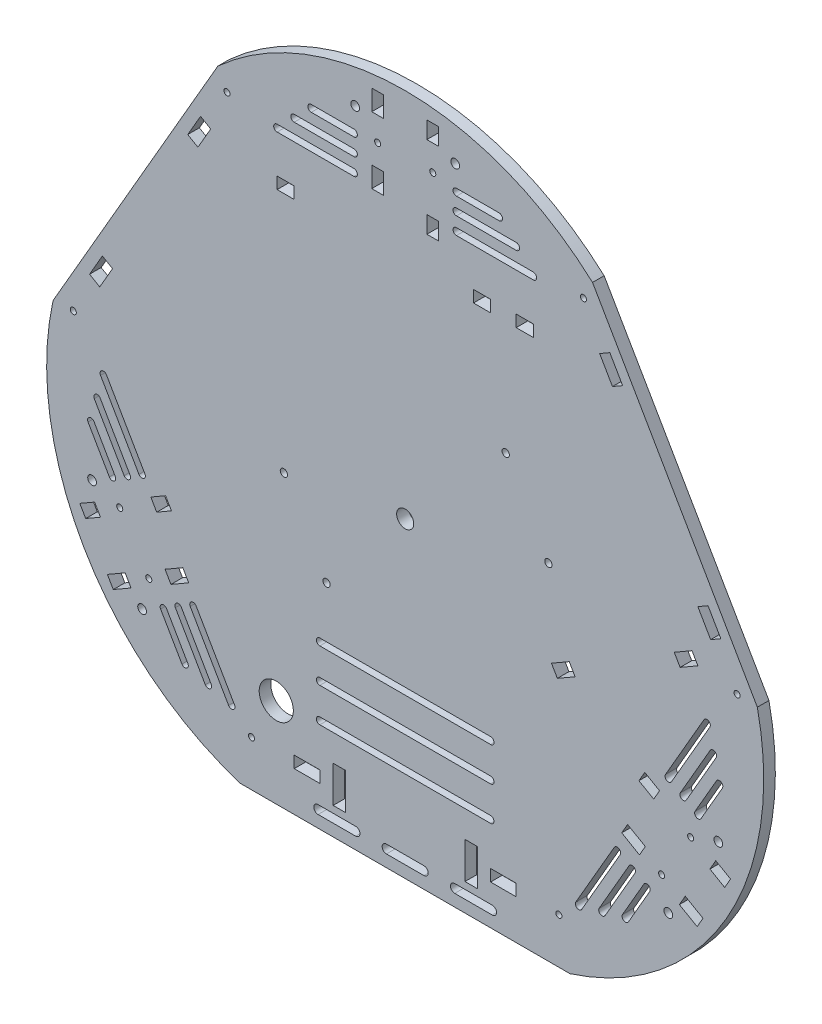
from build123d import *

# Parameters (mm, degrees)
SKETCH1_R           = 5
BOSS_EXTRUDE1_DEPTH = 6.8
SKETCH2_R           = 1.775
CUT_EXTRUDE1_DEPTH  = 6.8
SKETCH3_R           = 1.775
SKETCH3_W           = 15
SKETCH3_H           = 6.88
SKETCH3_W_2         = 7.2
SKETCH3_H_2         = 21.4
CUT_EXTRUDE2_DEPTH  = 6.8
CUT_EXTRUDE3_DEPTH  = 6.8
CUT_EXTRUDE4_DEPTH  = 6.8
SKETCH6_R           = 1.775
CUT_EXTRUDE5_DEPTH  = 6.8
CIRPATTERN1_COUNT   = 3
SKETCH7_R           = 2.55
CUT_EXTRUDE6_DEPTH  = 6.8
CIRPATTERN2_COUNT   = 3
SKETCH8_W           = 10
SKETCH8_H           = 6.88
CUT_EXTRUDE7_DEPTH  = 6.8
SKETCH10_R          = 10
CUT_EXTRUDE9_DEPTH  = 6.8
SKETCH11_R          = 2.125
CUT_EXTRUDE10_DEPTH = 10
CUT_EXTRUDE11_DEPTH = 7.8
CIRPATTERN4_COUNT   = 3
LPATTERN1_COUNT     = 2
LPATTERN1_PITCH     = 20
LPATTERN1_COL_COUNT = 2
LPATTERN1_COL_PITCH = 20
CUT_EXTRUDE12_DEPTH = 7.8


with BuildPart() as part:
    # Sketch1 → Boss-Extrude1 (new body)
    with BuildSketch(Plane.XY):
        with BuildLine():
            Line((-96.50625, -182.3938), (96.50625, -182.3938))
            ThreePointArc((96.50625, -182.3938), (188.115509518, -108.608540059), (206.210789293, 7.620035876))
            Line((206.210789293, 7.620035876), (109.704539293, 174.773764124))
            ThreePointArc((109.704539293, 174.773764124), (0, 217.217080118), (-109.704539293, 174.773764124))
            Line((-109.704539293, 174.773764124), (-206.210789293, 7.620035876))
            ThreePointArc((-206.210789293, 7.620035876), (-188.115509518, -108.608540059), (-96.50625, -182.3938))
        make_face()
        Circle(SKETCH1_R, mode=Mode.SUBTRACT)
    extrude(amount=BOSS_EXTRUDE1_DEPTH)

    # Sketch2 → Cut-Extrude1 (cut)
    with BuildSketch(Plane.XY.offset(6.8)):
        with Locations((-104.349371779, 164.169186341)):
            Circle(SKETCH2_R)
        with Locations((-194.349371779, 8.284613659)):
            Circle(SKETCH2_R)
        Polygon((-119.828499168, 144.238551246), (-127.328499168, 131.248170189), (-121.37024439, 127.808170189), (-113.87024439, 140.798551246), align=None)
        Polygon((-177.328499168, 44.645629811), (-171.37024439, 41.205629811), (-178.87024439, 28.215248754), (-184.828499168, 31.655248754), align=None)
    cut_extrude1 = extrude(amount=-CUT_EXTRUDE1_DEPTH, mode=Mode.SUBTRACT)

    # Sketch3 → Cut-Extrude2 (cut)
    with BuildSketch(Plane.XY.offset(6.8)):
        with Locations((-90, -155.7038)):
            Circle(SKETCH3_R)
        with Locations((-57.5, -155.7038)):
            Rectangle(SKETCH3_W, SKETCH3_H)
        with Locations((-38.6, -155.7038)):
            Rectangle(SKETCH3_W_2, SKETCH3_H_2)
    cut_extrude2 = extrude(amount=-CUT_EXTRUDE2_DEPTH, mode=Mode.SUBTRACT)

    # Sketch4 → Cut-Extrude3 (cut)
    with BuildSketch(Plane.XY.offset(6.8)):
        with BuildLine():
            Line((11, -175.3938), (-11, -175.3938))
            ThreePointArc((-11, -175.3938), (-13.5, -172.8938), (-11, -170.3938))
            Line((-11, -170.3938), (11, -170.3938))
            ThreePointArc((11, -170.3938), (13.5, -172.8938), (11, -175.3938))
        make_face()
        with BuildLine():
            Line((-29, -175.3938), (-51, -175.3938))
            ThreePointArc((-51, -175.3938), (-53.5, -172.8938), (-51, -170.3938))
            Line((-51, -170.3938), (-29, -170.3938))
            ThreePointArc((-29, -170.3938), (-26.5, -172.8938), (-29, -175.3938))
        make_face()
    cut_extrude3 = extrude(amount=-CUT_EXTRUDE3_DEPTH, mode=Mode.SUBTRACT)

    # Sketch5 → Cut-Extrude4 (cut)
    with BuildSketch(Plane.XY.offset(6.8)):
        with BuildLine():
            Line((50, -109.3938), (-50, -109.3938))
            ThreePointArc((-50, -109.3938), (-52, -107.3938), (-50, -105.3938))
            Line((-50, -105.3938), (50, -105.3938))
            ThreePointArc((50, -105.3938), (52, -107.3938), (50, -109.3938))
        make_face()
    cut_extrude4 = extrude(amount=-CUT_EXTRUDE4_DEPTH, mode=Mode.SUBTRACT)

    # Mirror1: Cut-Extrude1, Cut-Extrude2, Cut-Extrude3 across plane
    add(cut_extrude1.mirror(Plane(origin=(0, 0, 0), x_dir=(0, 0, 1), z_dir=(1, 0, 0))), mode=Mode.SUBTRACT)
    add(cut_extrude2.mirror(Plane(origin=(0, 0, 0), x_dir=(0, 0, 1), z_dir=(1, 0, 0))), mode=Mode.SUBTRACT)
    add(cut_extrude3.mirror(Plane(origin=(0, 0, 0), x_dir=(0, 0, 1), z_dir=(1, 0, 0))), mode=Mode.SUBTRACT)

    # Sketch6 → Cut-Extrude5 (cut)
    with BuildSketch(Plane.XY.offset(6.8)):
        with Locations((-150.152841271, -105.327650017)):
            Circle(SKETCH6_R)
        with Locations((-167.158866675, -77.872349983)):
            Circle(SKETCH6_R)
        Polygon((-187.08950177, -93.351477372), (-178.429247732, -88.351477372), (-181.869247732, -82.393222594), (-190.52950177, -87.393222594), align=None)
        Polygon((-174.38950177, -115.348522628), (-170.94950177, -121.306777406), (-160.557196924, -115.306777406), (-163.997196924, -109.348522628), align=None)
        Polygon((-148.960282388, -63.393222594), (-140.30002835, -58.393222594), (-136.86002835, -64.351477372), (-145.520282388, -69.351477372), align=None)
        Polygon((-140.614511022, -95.848522628), (-130.222206177, -89.848522628), (-126.782206177, -95.806777406), (-137.174511022, -101.806777406), align=None)
    cut_extrude5 = extrude(amount=-CUT_EXTRUDE5_DEPTH, mode=Mode.SUBTRACT)

    # Mirror2: Cut-Extrude5 across plane
    add(cut_extrude5.mirror(Plane(origin=(0, 0, 0), x_dir=(0, 0, 1), z_dir=(1, 0, 0))), mode=Mode.SUBTRACT)

    # CirPattern1: Cut-Extrude5 ×3 about axis, 1 skipped
    cirpattern1_axis = Axis((0, 0, 6.8), (0, 0, 1))
    add([cut_extrude5.rotate(cirpattern1_axis, i * 360 / CIRPATTERN1_COUNT) for i in range(1, CIRPATTERN1_COUNT) if i not in (1,)], mode=Mode.SUBTRACT)

    # Sketch7 → Cut-Extrude6 (cut)
    with BuildSketch(Plane.XY.offset(6.8)):
        with Locations((-154.066728647, -122.769878732)):
            Circle(SKETCH7_R)
        with Locations((-183.355198125, -72.040761521)):
            Circle(SKETCH7_R)
    cut_extrude6 = extrude(amount=-CUT_EXTRUDE6_DEPTH, mode=Mode.SUBTRACT)

    # CirPattern2: Cut-Extrude6 ×3 about axis
    cirpattern2_axis = Axis((0, 0, 0), (0, 0, 1))
    for i in range(1, CIRPATTERN2_COUNT):
        add(cut_extrude6.rotate(cirpattern2_axis, i * 360 / CIRPATTERN2_COUNT), mode=Mode.SUBTRACT)

    # Sketch8 → Cut-Extrude7 (cut)
    with BuildSketch(Plane.XY.offset(6.8)):
        with Locations((70, 132.94)):
            Rectangle(SKETCH8_W, SKETCH8_H)
        with Locations((45, 132.94)):
            Rectangle(SKETCH8_W, SKETCH8_H)
        with Locations((-70, 132.94)):
            Rectangle(SKETCH8_W, SKETCH8_H)
    extrude(amount=-CUT_EXTRUDE7_DEPTH, mode=Mode.SUBTRACT)

    # Sketch10 → Cut-Extrude9 (cut)
    with BuildSketch(Plane.XY.offset(6.8)):
        with Locations((-75.5, -130)):
            Circle(SKETCH10_R)
    extrude(amount=-CUT_EXTRUDE9_DEPTH, mode=Mode.SUBTRACT)

    # Sketch11 → Cut-Extrude10 (cut)
    with BuildSketch(Plane(origin=(0, 0, 0), x_dir=(-1, 0, 0), z_dir=(0, 0, -1))):
        with Locations((71.048686653, -12.152464905)):
            Circle(SKETCH11_R)
        with Locations((46.048686653, -55.453735095)):
            Circle(SKETCH11_R)
        with Locations((-83.855123914, 19.546264905)):
            Circle(SKETCH11_R)
        with Locations((-58.855123914, 62.847535095)):
            Circle(SKETCH11_R)
    extrude(amount=-CUT_EXTRUDE10_DEPTH, mode=Mode.SUBTRACT)

    # Sketch12 → Cut-Extrude11 (cut, through all)
    with BuildSketch(Plane.XY.offset(6.8)):
        with BuildLine():
            Line((30, 162.7), (75, 162.7))
            ThreePointArc((75, 162.7), (77, 160.7), (75, 158.7))
            Line((75, 158.7), (30, 158.7))
            ThreePointArc((30, 158.7), (28, 160.7), (30, 162.7))
        make_face()
        with BuildLine():
            Line((65, 168.7), (30, 168.7))
            ThreePointArc((30, 168.7), (28, 170.7), (30, 172.7))
            Line((30, 172.7), (65, 172.7))
            ThreePointArc((65, 172.7), (67, 170.7), (65, 168.7))
        make_face()
        with BuildLine():
            Line((55, 178.7), (30, 178.7))
            ThreePointArc((30, 178.7), (28, 180.7), (30, 182.7))
            Line((30, 182.7), (55, 182.7))
            ThreePointArc((55, 182.7), (57, 180.7), (55, 178.7))
        make_face()
        with BuildLine():
            Line((-30, 162.7), (-75, 162.7))
            ThreePointArc((-75, 162.7), (-77, 160.7), (-75, 158.7))
            Line((-75, 158.7), (-30, 158.7))
            ThreePointArc((-30, 158.7), (-28, 160.7), (-30, 162.7))
        make_face()
        with BuildLine():
            Line((-65, 168.7), (-30, 168.7))
            ThreePointArc((-30, 168.7), (-28, 170.7), (-30, 172.7))
            Line((-30, 172.7), (-65, 172.7))
            ThreePointArc((-65, 172.7), (-67, 170.7), (-65, 168.7))
        make_face()
        with BuildLine():
            Line((-55, 178.7), (-30, 178.7))
            ThreePointArc((-30, 178.7), (-28, 180.7), (-30, 182.7))
            Line((-30, 182.7), (-55, 182.7))
            ThreePointArc((-55, 182.7), (-57, 180.7), (-55, 178.7))
        make_face()
    cut_extrude11 = extrude(amount=-CUT_EXTRUDE11_DEPTH, mode=Mode.SUBTRACT)

    # CirPattern4: Cut-Extrude11 ×3 about axis
    cirpattern4_axis = Axis((0, 0, 0), (0, 0, 1))
    for i in range(1, CIRPATTERN4_COUNT):
        add(cut_extrude11.rotate(cirpattern4_axis, i * 360 / CIRPATTERN4_COUNT), mode=Mode.SUBTRACT)

    # LPattern1: Cut-Extrude4 ×2
    with Locations(*[(0, i * LPATTERN1_PITCH, 0) for i in range(1, LPATTERN1_COUNT)]):
        add(cut_extrude4, mode=Mode.SUBTRACT)

    # LPattern1 col: Cut-Extrude4 ×2
    with Locations(*[(0, -i * LPATTERN1_COL_PITCH, 0) for i in range(1, LPATTERN1_COL_COUNT)]):
        add(cut_extrude4, mode=Mode.SUBTRACT)

    # Sketch14 → Cut-Extrude12 (cut, through all)
    with BuildSketch(Plane(origin=(0, 0, 0), x_dir=(-1, 0, 0), z_dir=(0, 0, -1))):
        Polygon((-171.379863333, 11.188969312), (-167.939863333, 17.14722409), (-157.547558488, 11.14722409), (-160.987558488, 5.188969312), align=None)
        Polygon((-85.667449974, -30.35277591), (-89.107449974, -36.311030688), (-99.499754819, -30.311030688), (-96.059754819, -24.35277591), align=None)
    extrude(amount=-CUT_EXTRUDE12_DEPTH, mode=Mode.SUBTRACT)


solid = part.part
